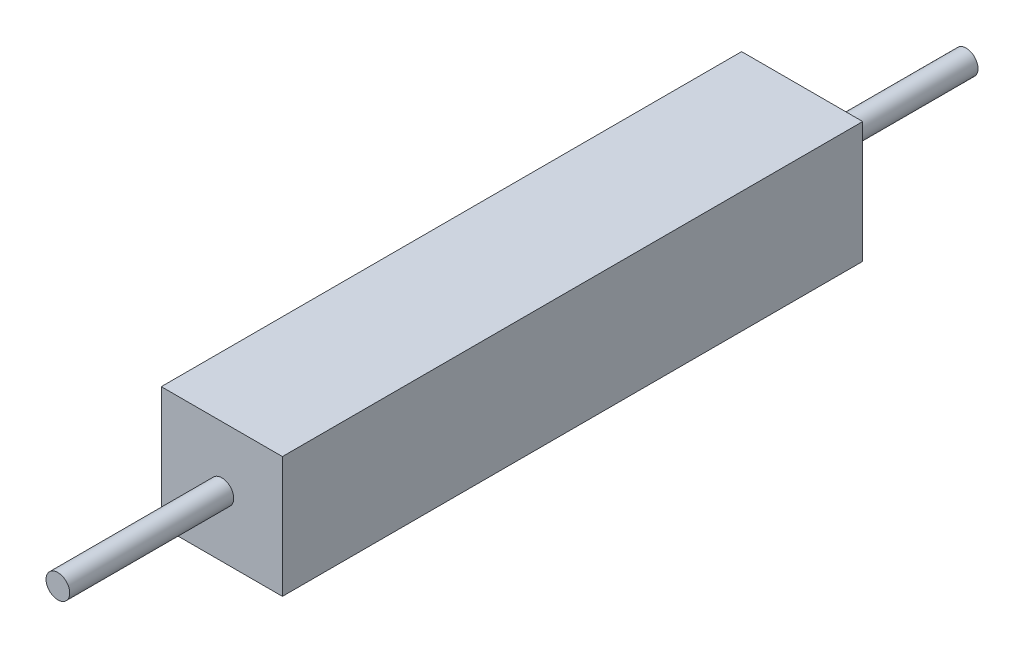
from build123d import *

# Parameters (mm, degrees)
SKETCH_1_W      = 2.4
SKETCH_1_H      = 2.4
EXTRUDE_1_DEPTH = 11.5
SKETCH_2_R      = 0.235
EXTRUDE_2_DEPTH = 3.25
SKETCH_3_R      = 0.235
EXTRUDE_3_DEPTH = 3.25


with BuildPart() as part:
    # ｽｹｯﾁ1 → ﾎﾞｽ - 押し出し1 (new body)
    with BuildSketch(Plane.XY):
        with Locations((1.2, 1.2)):
            Rectangle(SKETCH_1_W, SKETCH_1_H)
    extrude(amount=EXTRUDE_1_DEPTH)

    # ｽｹｯﾁ2 → ﾎﾞｽ - 押し出し2 (add)
    with BuildSketch(Plane.XY.offset(11.5)):
        with Locations((1.2, 1.2)):
            Circle(SKETCH_2_R)
    extrude(amount=EXTRUDE_2_DEPTH)

    # ｽｹｯﾁ3 → ﾎﾞｽ - 押し出し3 (add)
    with BuildSketch(Plane(origin=(0, 0, 0), x_dir=(-1, 0, 0), z_dir=(0, 0, -1))):
        with Locations((-1.2, 1.2)):
            Circle(SKETCH_3_R)
    extrude(amount=EXTRUDE_3_DEPTH)


solid = part.part
